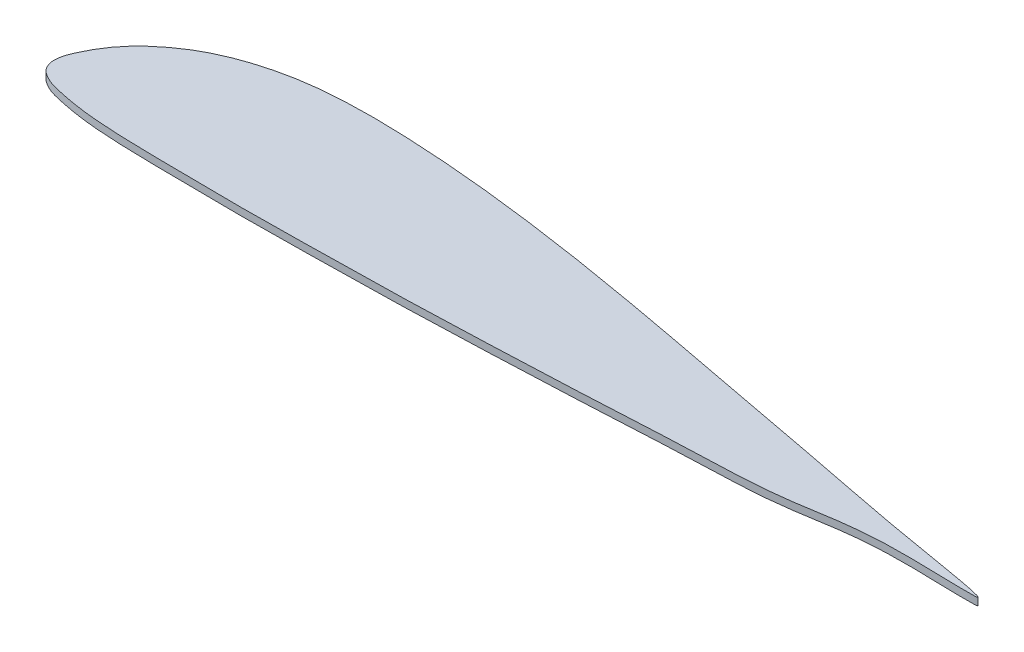
from build123d import *

# Parameters (mm, degrees)
BOSS_EXTRUDE3_DEPTH = 4


with BuildPart() as part:
    # Sketch2 → Boss-Extrude3 (new body)
    with BuildSketch(Plane(origin=(0, 0, 0), x_dir=(1, 0, 0), z_dir=(0, 1, 0))):
        with BuildLine():
            add(Edge.make_bspline(
                [(100, 0), (100.314162405, 1.255177455), (42.118914869, 10.385857724), (2.112554351, 18.766731784), (-50.569132274, 28.54721514), (-99.806676328, 38.038750055), (-149.916309846, 47.243974456), (-199.836765033, 54.870124019), (-241.592788118, 59.288086168), (-274.981335377, 61.094011167), (-300.043563288, 61.279508353), (-325.339866278, 59.157626311), (-347.236505465, 53.585974056), (-363.86992671, 46.321341465), (-375.529285945, 38.704501831), (-383.863414123, 31.510343479), (-390.462113476, 23.922874618), (-394.547433257, 17.588014886), (-398.444478298, 9.748717849), (-401.373466064, 1.939786055), (-398.387925991, -4.929956297), (-394.359570071, -7.766379494), (-390.196284637, -9.902011013), (-383.374621005, -11.571994592), (-375.057625707, -13.257597207), (-363.370532589, -14.804148864), (-346.686488623, -15.916490786), (-325.001284152, -16.261549613), (-300.001488083, -16.58995368), (-274.998479083, -16.678574575), (-241.666940865, -16.168078434), (-199.977290941, -15.594013963), (-150.031486347, -13.739585537), (-99.839642638, -11.64539667), (-50.563700775, -8.676467657), (2.250908778, -7.644478949), (42.087300725, 2.704851567), (99.691359172, -1.233117023), (100, 0)],
                knots=[0, 0, 0, 0, 0.049040866, 0.098081731, 0.147122597, 0.196163463, 0.245116686, 0.293834629, 0.342263553, 0.366385573, 0.390475046, 0.414675268, 0.439565651, 0.455415353, 0.466907824, 0.479711554, 0.487090329, 0.495936907, 0.501323477, 0.512663454, 0.51831006, 0.521365152, 0.526751722, 0.531754914, 0.54158153, 0.551304728, 0.565797224, 0.589894838, 0.613986045, 0.638075566, 0.662166773, 0.710353523, 0.758560308, 0.806785868, 0.855025, 0.903284915, 0.951821054, 1, 1, 1, 1], degree=3))
        make_face()
    extrude(amount=BOSS_EXTRUDE3_DEPTH)


solid = part.part
